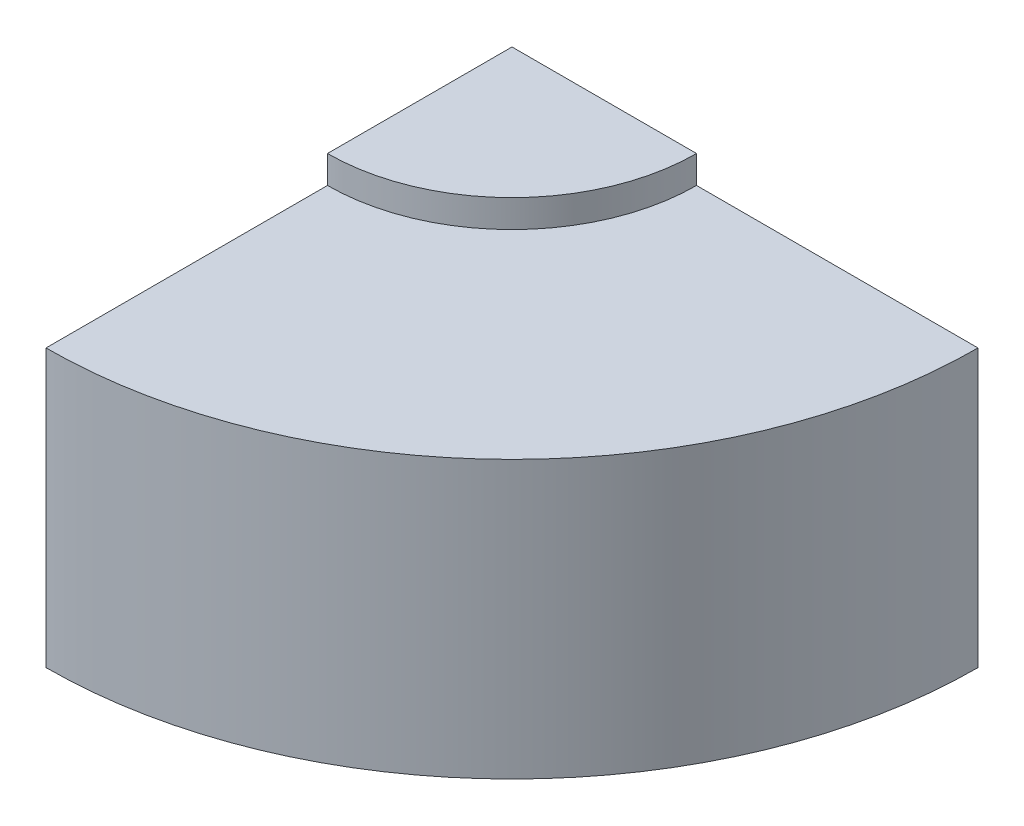
from build123d import *

# Parameters (mm, degrees)
SKETCH1_W      = 30
SKETCH1_H      = 40
SKETCH1_W_2    = 50
REVOLVE8_ANGLE = 90


with BuildPart() as part:
    # Sketch1 → Revolve8 (revolve)
    with BuildSketch(Plane.XY):
        Polygon((40, 34.160621762), (0, 34.160621762), (0, -41.839378238), (20, -41.839378238), (20, -31.839378238), (20, 29.160621762), (40, 29.160621762), align=None)
        Polygon((40, 28.160621762), (40, 29.160621762), (20, 29.160621762), (20, -31.839378238), (21, -31.839378238), (21, -21.839378238), (21, 18.160621762), (21, 28.160621762), align=None)
        Polygon((101, 28.160621762), (40, 28.160621762), (21, 28.160621762), (21, 18.160621762), (51, 18.160621762), (101, 18.160621762), align=None)
        Polygon((21, -21.839378238), (21, -31.839378238), (101, -31.839378238), (101, -21.839378238), (51, -21.839378238), align=None)
        with Locations((36, -1.839378238)):
            Rectangle(SKETCH1_W, SKETCH1_H)
        with Locations((76, -1.839378238)):
            Rectangle(SKETCH1_W_2, SKETCH1_H)
    revolve(axis=Axis((0, 34.160621762, 0), (0, -1, 0)), revolution_arc=REVOLVE8_ANGLE)


solid = part.part
